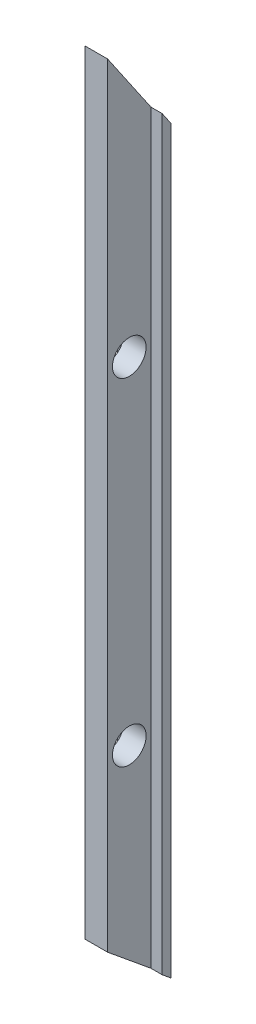
from build123d import *

# Parameters (mm, degrees)
SKETCH1_W             = 4
SKETCH1_H             = 66
BOSS_EXTRUDE1_DEPTH   = 1
SKETCH1_2_W           = 4
SKETCH1_2_H           = 66
BOSS_EXTRUDE2_DEPTH   = 1.36844839
SKETCH4_W             = 2
SKETCH4_H             = 66.494663906
BOSS_EXTRUDE3_DEPTH   = 5
SKETCH4_2_W           = 2
SKETCH4_2_H           = 66.494663906
BOSS_EXTRUDE4_DEPTH   = 6.842238407
F_3_0MM_DOWEL_HOLE1_D = 3


with BuildPart() as part:
    # Sketch1 → Boss-Extrude1 (new, along a direction that is not the sketch's normal)
    with BuildSketch(Plane.XY):
        Rectangle(SKETCH1_W, SKETCH1_H)
    extrude(amount=BOSS_EXTRUDE1_DEPTH, dir=(0, 0.6347305132022716, 0.7727335734973478))

    # Sketch1_2 → Boss-Extrude2 (add, along a direction that is not the sketch's normal)
    with BuildSketch(Plane.XY):
        Rectangle(SKETCH1_2_W, SKETCH1_2_H)
    extrude(amount=BOSS_EXTRUDE2_DEPTH, dir=(0, 0.8253106586930028, 0.5646789500660725))

    # Sketch4 → Boss-Extrude3 (add, along a direction that is not the sketch's normal)
    with BuildSketch(Plane.XY.offset(0.772733573)):
        with Locations((0, 0.882062466)):
            Rectangle(SKETCH4_W, SKETCH4_H)
    extrude(amount=BOSS_EXTRUDE3_DEPTH, dir=(0, 0.6347305132022716, 0.7727335734973478))

    # Sketch4_2 → Boss-Extrude4 (add, along a direction that is not the sketch's normal)
    with BuildSketch(Plane.XY.offset(0.772733573)):
        with Locations((0, 0.882062466)):
            Rectangle(SKETCH4_2_W, SKETCH4_2_H)
    extrude(amount=BOSS_EXTRUDE4_DEPTH, dir=(0, 0.8253106586930028, 0.5646789500660725))

    # Ø3.0mm Dowel Hole1 (through all)
    with Locations(Plane.ZY.offset(1)):
        with Locations((2.704567507, -14.191616921), (2.704567507, 15.808383079)):
            Hole(F_3_0MM_DOWEL_HOLE1_D / 2)


solid = part.part
